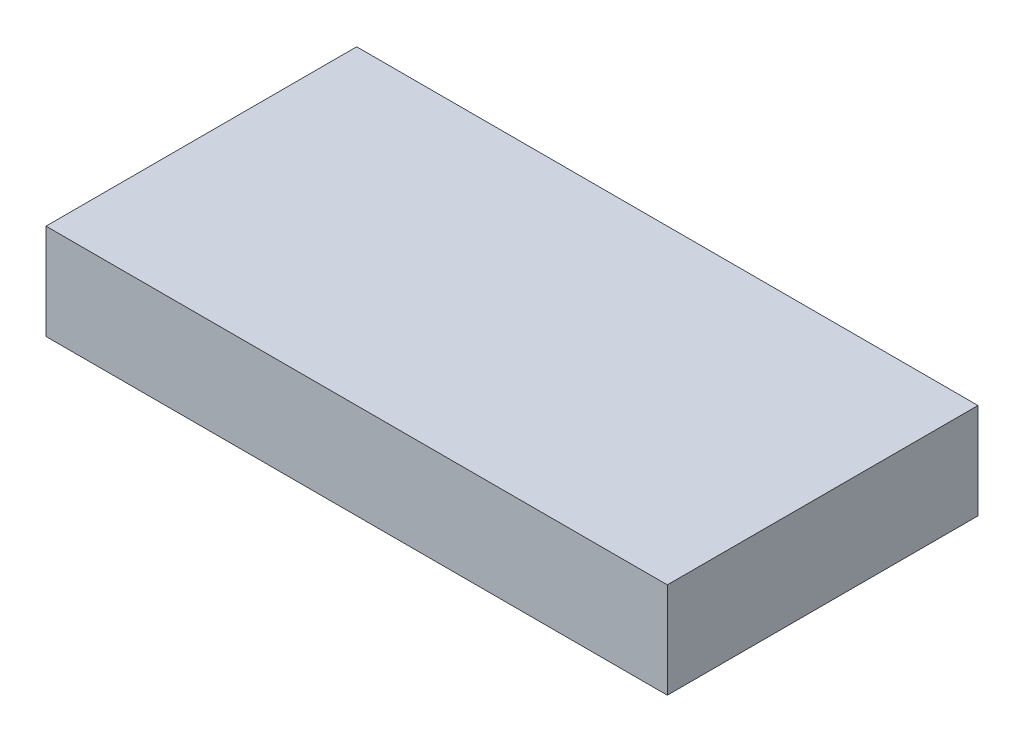
from build123d import *

# Parameters (mm, degrees)
SKETCH1_W           = 130
SKETCH1_H           = 65
BOSS_EXTRUDE1_DEPTH = 20


with BuildPart() as part:
    # Sketch1 → Boss-Extrude1 (new body)
    with BuildSketch(Plane(origin=(0, 0, 0), x_dir=(1, 0, 0), z_dir=(0, 1, 0))):
        with Locations((65, 32.5)):
            Rectangle(SKETCH1_W, SKETCH1_H)
    extrude(amount=BOSS_EXTRUDE1_DEPTH)


solid = part.part
